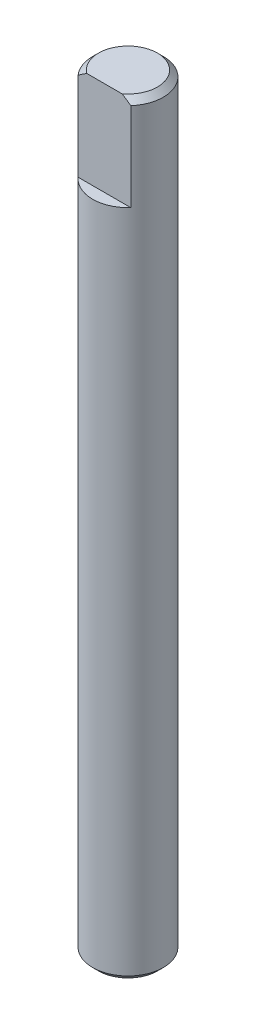
from build123d import *

# Parameters (mm, degrees)
SKETCH1_R           = 3
BOSS_EXTRUDE1_DEPTH = 65
CUT_EXTRUDE1_DEPTH  = 8
CHAMFER1_SIZE       = 0.5


with BuildPart() as part:
    # Sketch1 → Boss-Extrude1 (new body)
    with BuildSketch(Plane(origin=(0, 0, 0), x_dir=(1, 0, 0), z_dir=(0, 1, 0))):
        Circle(SKETCH1_R)
    extrude(amount=BOSS_EXTRUDE1_DEPTH)

    # Sketch2 → Cut-Extrude1 (cut)
    with BuildSketch(Plane(origin=(0, 65, 0), x_dir=(1, 0, 0), z_dir=(0, 1, 0))):
        with BuildLine():
            Line((-2.236067977, -2), (2.236067977, -2))
            ThreePointArc((2.236067977, -2), (0, -3), (-2.236067977, -2))
        make_face()
    extrude(amount=-CUT_EXTRUDE1_DEPTH, mode=Mode.SUBTRACT)

    # Chamfer1
    chamfer1_edges = [part.edges().sort_by_distance(p)[0] for p in [
        (-3, 0, 0),
        (-1.070466269, 65, -2.802517077),
    ]]
    chamfer(chamfer1_edges, length=CHAMFER1_SIZE)


solid = part.part
